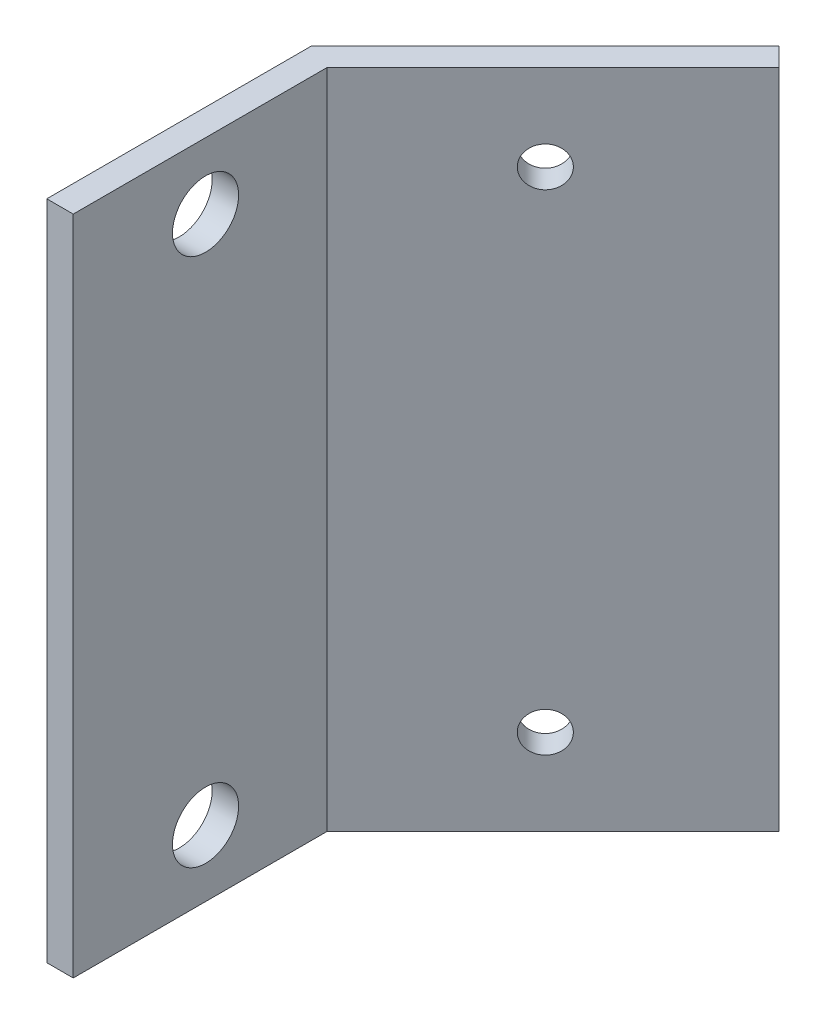
from build123d import *

# Parameters (mm, degrees)
EXTRUSION1_DEPTH = 50
EXTRUSION2_REACH = 21.092
ESQUISSE3_R      = 2.5
EXTRUSION3_REACH = 29.642
ESQUISSE4_R      = 1.5


with BuildPart() as part:
    # Esquisse1 → Extrusion1 (new body)
    with BuildSketch(Plane(origin=(0, 0, 0), x_dir=(1, 0, 0), z_dir=(0, 1, 0))):
        Polygon((0, 0), (0, 20), (17.67766953, 37.67766953), (19.091883092, 36.263455967), (2, 19.171572875), (2, 0), align=None)
    extrude(amount=EXTRUSION1_DEPTH)

    # Esquisse3 → Extrusion2 (cut, up to next)
    with BuildSketch(Plane.ZY, mode=Mode.PRIVATE) as extrusion2_sk1:
        with Locations((-10, 5)):
            Circle(ESQUISSE3_R)
    extrusion2_tool1 = extrude(extrusion2_sk1.sketch, amount=-EXTRUSION2_REACH, mode=Mode.PRIVATE) & part.part
    add(extrusion2_tool1.solids().sort_by_distance((0, 5, -10))[0], mode=Mode.SUBTRACT)
    # Esquisse3 → Extrusion2 (cut, up to next)
    with BuildSketch(Plane.ZY, mode=Mode.PRIVATE) as extrusion2_sk2:
        with Locations((-10, 45)):
            Circle(ESQUISSE3_R)
    extrusion2_tool2 = extrude(extrusion2_sk2.sketch, amount=-EXTRUSION2_REACH, mode=Mode.PRIVATE) & part.part
    add(extrusion2_tool2.solids().sort_by_distance((0, 45, -10))[0], mode=Mode.SUBTRACT)

    # Esquisse4 → Extrusion3 (cut, up to next)
    with BuildSketch(Plane(origin=(-10, 0, -10), x_dir=(-0.707106781, 0, 0.707106781), z_dir=(-0.707106781, 0, -0.707106781)), mode=Mode.PRIVATE) as extrusion3_sk1:
        with Locations((-26.642135624, 43.5)):
            Circle(ESQUISSE4_R)
    extrusion3_tool1 = extrude(extrusion3_sk1.sketch, amount=-EXTRUSION3_REACH, mode=Mode.PRIVATE) & part.part
    add(extrusion3_tool1.solids().sort_by_distance((8.838835, 43.5, -28.838835))[0], mode=Mode.SUBTRACT)
    # Esquisse4 → Extrusion3 (cut, up to next)
    with BuildSketch(Plane(origin=(-10, 0, -10), x_dir=(-0.707106781, 0, 0.707106781), z_dir=(-0.707106781, 0, -0.707106781)), mode=Mode.PRIVATE) as extrusion3_sk2:
        with Locations((-26.642135624, 6.5)):
            Circle(ESQUISSE4_R)
    extrusion3_tool2 = extrude(extrusion3_sk2.sketch, amount=-EXTRUSION3_REACH, mode=Mode.PRIVATE) & part.part
    add(extrusion3_tool2.solids().sort_by_distance((8.838835, 6.5, -28.838835))[0], mode=Mode.SUBTRACT)


solid = part.part
